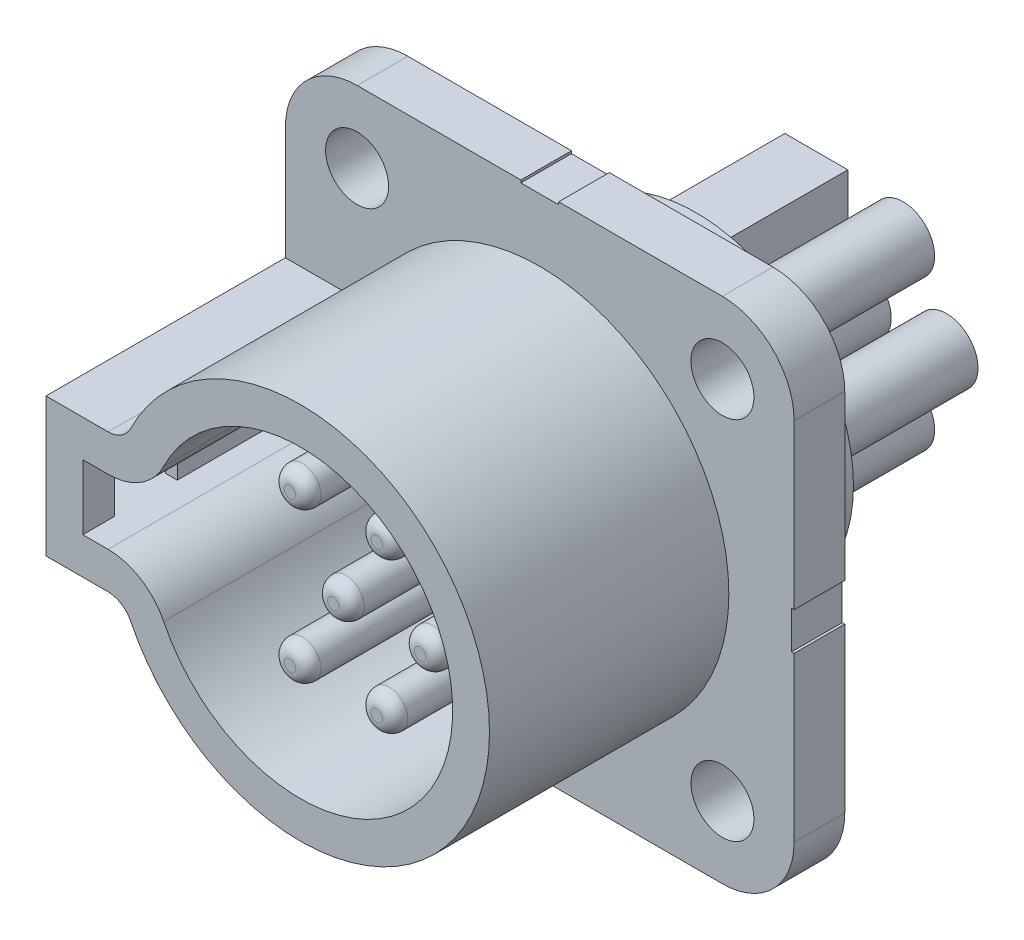
from build123d import *

# Parameters (mm, degrees)
SKETCH1_W                = 20.19
SKETCH1_H                = 20.19
BOSS_EXTRUDE1_DEPTH      = 2.01
SKETCH2_R                = 1.25
CUT_EXTRUDE1_DEPTH       = 2.01
FILLET1_R                = 2.85
BOSS_EXTRUDE2_DEPTH      = 9.5
SKETCH5_W                = 10.26
SKETCH5_H                = 2.578976508
CUT_EXTRUDE2_DEPTH       = 1
CUT_EXTRUDE3_REACH       = 21.19
SKETCH6_W                = 2.5
SKETCH6_H                = 2.578976508
SKETCH7_R                = 6.25
BOSS_EXTRUDE3_DEPTH      = 4.19
SKETCH8_R                = 0.73
BOSS_EXTRUDE4_DEPTH      = 8.19
BOSS_EXTRUDE4_DEPTH_BACK = 7
FILLET2_R                = 0.5
SKETCH9_R                = 1.25
SKETCH9_R_2              = 1
SKETCH9_W                = 2.5
SKETCH9_H                = 2.5
SKETCH9_W_2              = 2
SKETCH9_H_2              = 2
EXTRUDE_THIN1_DEPTH      = 6.5
SKETCH10_W               = 1.5
SKETCH10_H               = 2.01
CUT_EXTRUDE4_DEPTH       = 0.1
SKETCH12_W               = 2.01
SKETCH12_H               = 1.5
CUT_EXTRUDE5_DEPTH       = 0.1


with BuildPart() as part:
    # Sketch1 → Boss-Extrude1 (new body)
    with BuildSketch(Plane.XY):
        Rectangle(SKETCH1_W, SKETCH1_H)
    extrude(amount=BOSS_EXTRUDE1_DEPTH)

    # Sketch2 → Cut-Extrude1 (cut)
    with BuildSketch(Plane.XY.offset(2.01)):
        with Locations((-7.25, 7.25)):
            Circle(SKETCH2_R)
        with Locations((7.25, 7.25)):
            Circle(SKETCH2_R)
        with Locations((7.25, -7.25)):
            Circle(SKETCH2_R)
        with Locations((-7.25, -7.25)):
            Circle(SKETCH2_R)
    extrude(amount=-CUT_EXTRUDE1_DEPTH, mode=Mode.SUBTRACT)

    # Fillet1
    fillet1_edges = [part.edges().sort_by_distance(p)[0] for p in [
        (10.095, -10.095, 1.005),
        (-10.095, -10.095, 1.005),
        (-10.095, 10.095, 1.005),
        (10.095, 10.095, 1.005),
    ]]
    fillet(fillet1_edges, radius=FILLET1_R)

    # Sketch4 → Boss-Extrude2 (add)
    with BuildSketch(Plane.XY.offset(2.01)):
        with BuildLine():
            Line((-10.095, -2.749488254), (-10.095, 2.749488254))
            Line((-10.095, 2.749488254), (-7.633895652, 2.749488254))
            ThreePointArc((-7.633895652, 2.749488254), (-7.10515041, 2.900707677), (-6.736318268, 3.308631317))
            ThreePointArc((-6.736318268, 3.308631317), (7.505, 0), (-6.736318268, -3.308631317))
            ThreePointArc((-6.736318268, -3.308631317), (-7.10515041, -2.900707677), (-7.633895652, -2.749488254))
            Line((-7.633895652, -2.749488254), (-10.095, -2.749488254))
        make_face()
        with BuildLine():
            Line((-8.635, -1.289488254), (-8.635, 1.289488254))
            Line((-8.635, 1.289488254), (-7.633895652, 1.289488254))
            ThreePointArc((-7.633895652, 1.289488254), (-6.333182356, 1.661488034), (-5.425855287, 2.664980188))
            ThreePointArc((-5.425855287, 2.664980188), (6.045, 0), (-5.425855287, -2.664980188))
            ThreePointArc((-5.425855287, -2.664980188), (-6.333182356, -1.661488034), (-7.633895652, -1.289488254))
            Line((-7.633895652, -1.289488254), (-8.635, -1.289488254))
        make_face(mode=Mode.SUBTRACT)
    extrude(amount=BOSS_EXTRUDE2_DEPTH)

    # Sketch5 → Cut-Extrude2 (cut)
    with BuildSketch(Plane.ZY.offset(10.095)):
        with Locations((5.13, 0)):
            Rectangle(SKETCH5_W, SKETCH5_H)
    extrude(amount=-CUT_EXTRUDE2_DEPTH, mode=Mode.SUBTRACT)

    # Sketch6 → Cut-Extrude3 (cut, up to next)
    with BuildSketch(Plane.ZY.offset(9.095), mode=Mode.PRIVATE) as cut_extrude3_sk1:
        with Locations((9.01, 0)):
            Rectangle(SKETCH6_W, SKETCH6_H)
    cut_extrude3_tool1 = extrude(cut_extrude3_sk1.sketch, amount=-CUT_EXTRUDE3_REACH, mode=Mode.PRIVATE) & part.part
    add(cut_extrude3_tool1.solids().sort_by_distance((-9.095, 0, 9.01))[0], mode=Mode.SUBTRACT)

    # Sketch7 → Boss-Extrude3 (add)
    with BuildSketch(Plane(origin=(0, 0, 0), x_dir=(-1, 0, 0), z_dir=(0, 0, -1))):
        Circle(SKETCH7_R)
    extrude(amount=BOSS_EXTRUDE3_DEPTH)

    # Sketch8 → Boss-Extrude4 (add, two sides)
    with BuildSketch(Plane.XY.offset(2.01)) as boss_extrude4_sk:
        Circle(SKETCH8_R)
        with Locations((3.445, 0)):
            Circle(SKETCH8_R)
        with Locations((1.7225, 2.983457516)):
            Circle(SKETCH8_R)
        with Locations((-1.7225, 2.983457516)):
            Circle(SKETCH8_R)
        with Locations((1.7225, -2.983457516)):
            Circle(SKETCH8_R)
        with Locations((-1.7225, -2.983457516)):
            Circle(SKETCH8_R)
    extrude(amount=BOSS_EXTRUDE4_DEPTH)
    extrude(boss_extrude4_sk.sketch, amount=-BOSS_EXTRUDE4_DEPTH_BACK)

    # Fillet2
    fillet2_edges = [part.edges().sort_by_distance(p)[0] for p in [
        (-0.73, 0, 10.2),
        (2.715, 0, 10.2),
        (0.9925, 2.983457516, 10.2),
        (-2.4525, 2.983457516, 10.2),
        (0.9925, -2.983457516, 10.2),
        (-2.4525, -2.983457516, 10.2),
    ]]
    fillet(fillet2_edges, radius=FILLET2_R)

    # Sketch9 → Extrude-Thin1 (add)
    with BuildSketch(Plane(origin=(0, 0, -4.19), x_dir=(-1, 0, 0), z_dir=(0, 0, -1))):
        with Locations((-1.7225, 2.983457516)):
            Circle(SKETCH9_R)
        with Locations((-1.7225, 2.983457516)):
            Circle(SKETCH9_R_2, mode=Mode.SUBTRACT)
        Circle(SKETCH9_R)
        Circle(SKETCH9_R_2, mode=Mode.SUBTRACT)
        with Locations((-3.445, 0)):
            Circle(SKETCH9_R)
        with Locations((-3.445, 0)):
            Circle(SKETCH9_R_2, mode=Mode.SUBTRACT)
        with Locations((-1.7225, -2.983457516)):
            Circle(SKETCH9_R)
        with Locations((-1.7225, -2.983457516)):
            Circle(SKETCH9_R_2, mode=Mode.SUBTRACT)
        with Locations((1.7225, 2.983457516)):
            Rectangle(SKETCH9_W, SKETCH9_H)
        with Locations((1.7225, 2.983457516)):
            Rectangle(SKETCH9_W_2, SKETCH9_H_2, mode=Mode.SUBTRACT)
        with Locations((1.7225, -2.983457516)):
            Rectangle(SKETCH9_W, SKETCH9_H)
        with Locations((1.7225, -2.983457516)):
            Rectangle(SKETCH9_W_2, SKETCH9_H_2, mode=Mode.SUBTRACT)
    extrude(amount=EXTRUDE_THIN1_DEPTH)

    # Sketch10 → Cut-Extrude4 (cut)
    with BuildSketch(Plane(origin=(0, 10.095, 0), x_dir=(1, 0, 0), z_dir=(0, 1, 0))):
        with Locations((0, -1.005)):
            Rectangle(SKETCH10_W, SKETCH10_H)
    extrude(amount=-CUT_EXTRUDE4_DEPTH, mode=Mode.SUBTRACT)

    # Sketch12 → Cut-Extrude5 (cut)
    with BuildSketch(Plane(origin=(10.095, 0, 0), x_dir=(0, 0, -1), z_dir=(1, 0, 0))):
        with Locations((-1.005, 0)):
            Rectangle(SKETCH12_W, SKETCH12_H)
    extrude(amount=-CUT_EXTRUDE5_DEPTH, mode=Mode.SUBTRACT)


solid = part.part
